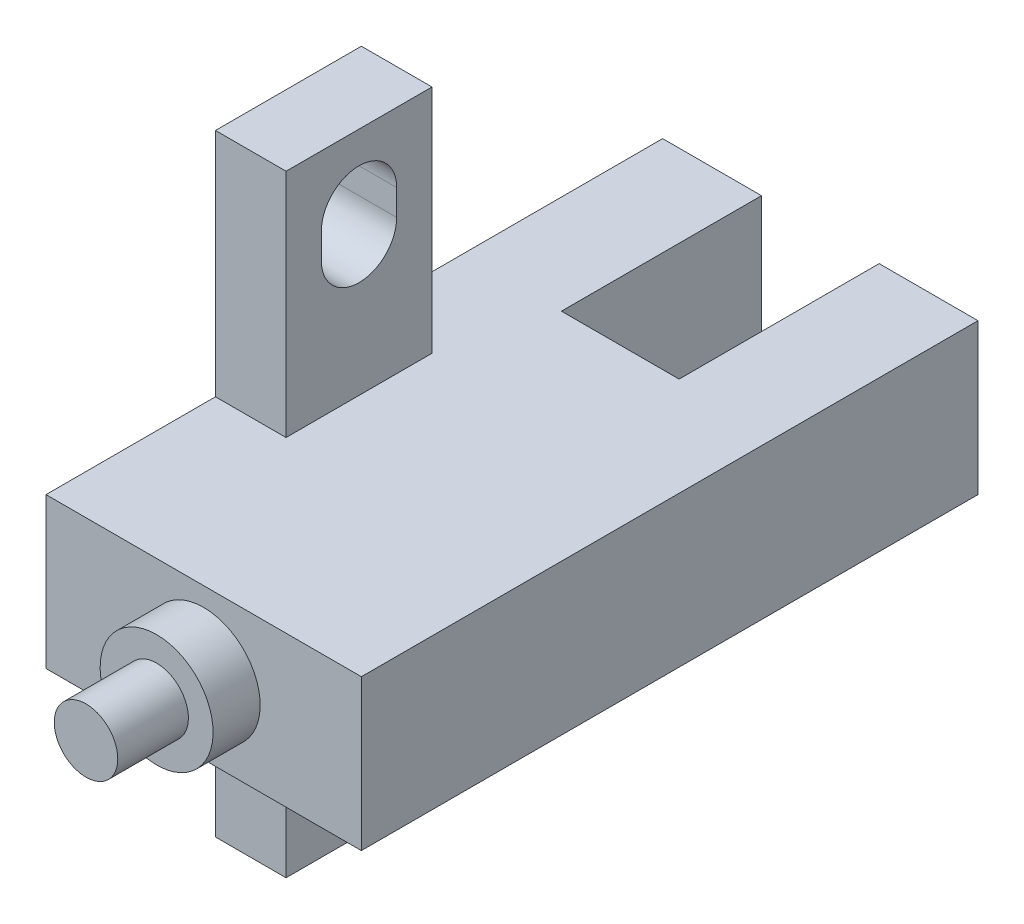
from build123d import *

# Parameters (mm, degrees)
SKETCH1_W           = 13.4
SKETCH1_H           = 26.2
BOSS_EXTRUDE1_DEPTH = 6.4
SKETCH2_W           = 5
SKETCH2_H           = 8.5
CUT_EXTRUDE1_DEPTH  = 6.4
SKETCH3_W           = 6.2
SKETCH3_H           = 26
BOSS_EXTRUDE2_DEPTH = 3
CUT_EXTRUDE2_DEPTH  = 4


with BuildPart() as part:
    # Sketch1 → Boss-Extrude1 (new body)
    with BuildSketch(Plane(origin=(0, 0, 0), x_dir=(1, 0, 0), z_dir=(0, 1, 0))):
        with Locations((0, 13.1)):
            Rectangle(SKETCH1_W, SKETCH1_H)
    extrude(amount=BOSS_EXTRUDE1_DEPTH)

    # Sketch2 → Cut-Extrude1 (cut)
    with BuildSketch(Plane(origin=(0, 6.4, 0), x_dir=(1, 0, 0), z_dir=(0, 1, 0))):
        with Locations((0, 21.95)):
            Rectangle(SKETCH2_W, SKETCH2_H)
    extrude(amount=-CUT_EXTRUDE1_DEPTH, mode=Mode.SUBTRACT)

    # Sketch3 → Boss-Extrude2 (add)
    with BuildSketch(Plane.ZY.offset(6.7)):
        with Locations((-10.3, 3.2)):
            Rectangle(SKETCH3_W, SKETCH3_H)
    extrude(amount=-BOSS_EXTRUDE2_DEPTH)

    # Sketch4 → Cut-Extrude2 (cut, through all)
    with BuildSketch(Plane(origin=(-3.7, 0, 0), x_dir=(0, 0, -1), z_dir=(1, 0, 0))):
        with BuildLine():
            Line((11.9, 13.25), (11.9, 12.15))
            ThreePointArc((11.9, 12.15), (10.3, 10.55), (8.7, 12.15))
            Line((8.7, 12.15), (8.7, 13.25))
            ThreePointArc((8.7, 13.25), (10.3, 14.85), (11.9, 13.25))
        make_face()
        with BuildLine():
            Line((11.9, -6.85), (11.9, -5.75))
            ThreePointArc((11.9, -5.75), (10.3, -4.15), (8.7, -5.75))
            Line((8.7, -5.75), (8.7, -6.85))
            ThreePointArc((8.7, -6.85), (10.3, -8.45), (11.9, -6.85))
        make_face()
    extrude(amount=-CUT_EXTRUDE2_DEPTH, mode=Mode.SUBTRACT)

    # Sketch5 → Revolve1 (revolve)
    with BuildSketch(Plane(origin=(0, 0, 0), x_dir=(0, 0, -1), z_dir=(1, 0, 0))):
        Polygon((0, 3.2), (0, 5.6), (-2, 5.6), (-2, 4.55), (-5, 4.55), (-5, 3.2), align=None)
    revolve(axis=Axis((0, 3.2, -27.354495769), (0, 0, 1)))


solid = part.part
